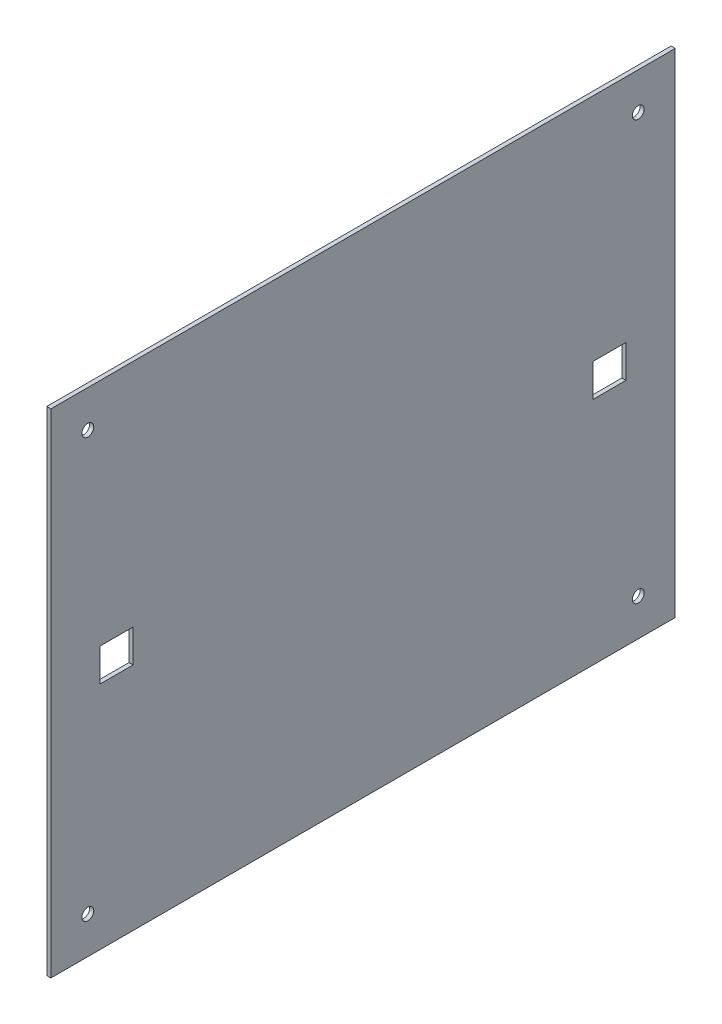
from build123d import *

# Parameters (mm, degrees)
SKETCH1_W           = 241.3
SKETCH1_H           = 190.5
BOSS_EXTRUDE1_DEPTH = 1.5875
SKETCH2_R           = 2.286
CUT_EXTRUDE1_DEPTH  = 2.5875
SKETCH3_W           = 12.7
SKETCH3_H           = 12.7
CUT_EXTRUDE2_DEPTH  = 2.5875


with BuildPart() as part:
    # Sketch1 → Boss-Extrude1 (new body)
    with BuildSketch(Plane(origin=(0, 0, 0), x_dir=(0, 0, -1), z_dir=(1, 0, 0))):
        with Locations((120.65, 95.25)):
            Rectangle(SKETCH1_W, SKETCH1_H)
    extrude(amount=BOSS_EXTRUDE1_DEPTH)

    # Sketch2 → Cut-Extrude1 (cut, through all)
    with BuildSketch(Plane(origin=(1.5875, 0, 0), x_dir=(0, 0, -1), z_dir=(1, 0, 0))):
        with Locations((227.0125, 14.2875)):
            Circle(SKETCH2_R)
        with Locations((227.0125, 176.2125)):
            Circle(SKETCH2_R)
        with Locations((14.2875, 14.2875)):
            Circle(SKETCH2_R)
        with Locations((14.2875, 176.2125)):
            Circle(SKETCH2_R)
    extrude(amount=-CUT_EXTRUDE1_DEPTH, mode=Mode.SUBTRACT)

    # Sketch3 → Cut-Extrude2 (cut, through all)
    with BuildSketch(Plane(origin=(1.5875, 0, 0), x_dir=(0, 0, -1), z_dir=(1, 0, 0))):
        with Locations((25.4, 95.25)):
            Rectangle(SKETCH3_W, SKETCH3_H)
        with Locations((215.9, 95.25)):
            Rectangle(SKETCH3_W, SKETCH3_H)
    extrude(amount=-CUT_EXTRUDE2_DEPTH, mode=Mode.SUBTRACT)


solid = part.part
